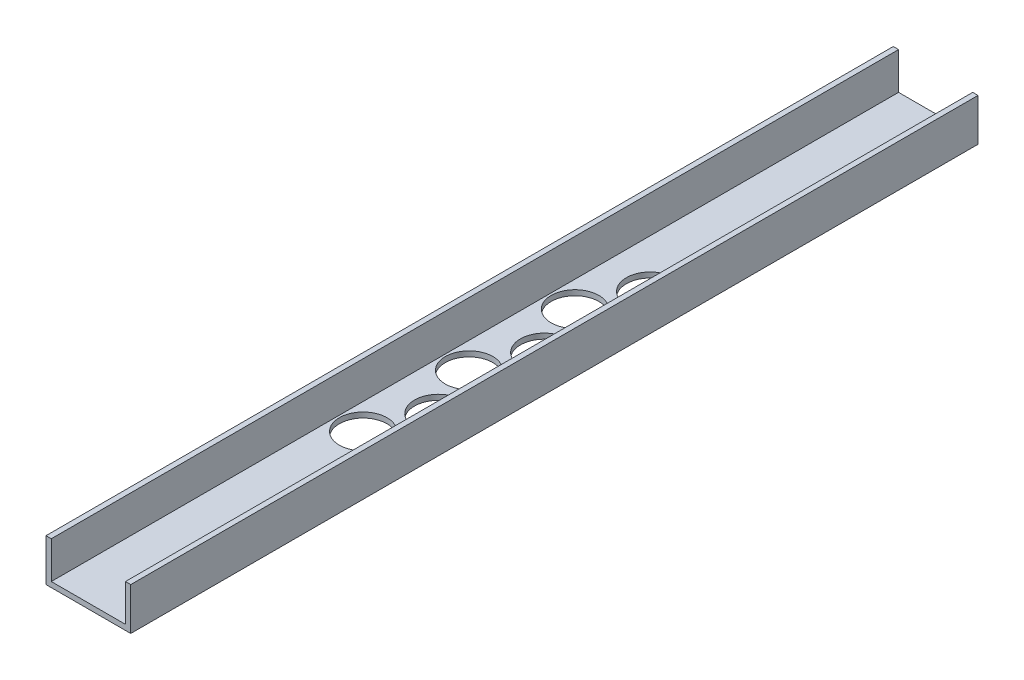
from build123d import *

# Parameters (mm, degrees)
BOSS_EXTRUDE1_DEPTH = 508
CUT_EXTRUDE1_REACH  = 5.175
SKETCH2_R           = 14.2875


with BuildPart() as part:
    # Sketch1 → Boss-Extrude1 (new body)
    with BuildSketch(Plane.XY):
        Polygon((47.625, 3.175), (47.625, 25.4), (50.8, 25.4), (50.8, 0), (0, 0), (0, 25.4), (3.175, 25.4), (3.175, 3.175), align=None)
    extrude(amount=BOSS_EXTRUDE1_DEPTH)

    # Sketch2 → Cut-Extrude1 (cut, up to next)
    with BuildSketch(Plane(origin=(0, 3.175, 0), x_dir=(1, 0, 0), z_dir=(0, 1, 0)), mode=Mode.PRIVATE) as cut_extrude1_sk1:
        with Locations((18.7325, -336.55)):
            Circle(SKETCH2_R)
    cut_extrude1_tool1 = extrude(cut_extrude1_sk1.sketch, amount=-CUT_EXTRUDE1_REACH, mode=Mode.PRIVATE) & part.part
    add(cut_extrude1_tool1.solids().sort_by_distance((18.7325, 3.175, 336.55))[0], mode=Mode.SUBTRACT)
    # Sketch2 → Cut-Extrude1 (cut, up to next)
    with BuildSketch(Plane(origin=(0, 3.175, 0), x_dir=(1, 0, 0), z_dir=(0, 1, 0)), mode=Mode.PRIVATE) as cut_extrude1_sk2:
        with Locations((32.0675, -304.8)):
            Circle(SKETCH2_R)
    cut_extrude1_tool2 = extrude(cut_extrude1_sk2.sketch, amount=-CUT_EXTRUDE1_REACH, mode=Mode.PRIVATE) & part.part
    add(cut_extrude1_tool2.solids().sort_by_distance((32.0675, 3.175, 304.8))[0], mode=Mode.SUBTRACT)
    # Sketch2 → Cut-Extrude1 (cut, up to next)
    with BuildSketch(Plane(origin=(0, 3.175, 0), x_dir=(1, 0, 0), z_dir=(0, 1, 0)), mode=Mode.PRIVATE) as cut_extrude1_sk3:
        with Locations((18.7325, -273.05)):
            Circle(SKETCH2_R)
    cut_extrude1_tool3 = extrude(cut_extrude1_sk3.sketch, amount=-CUT_EXTRUDE1_REACH, mode=Mode.PRIVATE) & part.part
    add(cut_extrude1_tool3.solids().sort_by_distance((18.7325, 3.175, 273.05))[0], mode=Mode.SUBTRACT)
    # Sketch2 → Cut-Extrude1 (cut, up to next)
    with BuildSketch(Plane(origin=(0, 3.175, 0), x_dir=(1, 0, 0), z_dir=(0, 1, 0)), mode=Mode.PRIVATE) as cut_extrude1_sk4:
        with Locations((32.0675, -241.3)):
            Circle(SKETCH2_R)
    cut_extrude1_tool4 = extrude(cut_extrude1_sk4.sketch, amount=-CUT_EXTRUDE1_REACH, mode=Mode.PRIVATE) & part.part
    add(cut_extrude1_tool4.solids().sort_by_distance((32.0675, 3.175, 241.3))[0], mode=Mode.SUBTRACT)
    # Sketch2 → Cut-Extrude1 (cut, up to next)
    with BuildSketch(Plane(origin=(0, 3.175, 0), x_dir=(1, 0, 0), z_dir=(0, 1, 0)), mode=Mode.PRIVATE) as cut_extrude1_sk5:
        with Locations((18.7325, -209.55)):
            Circle(SKETCH2_R)
    cut_extrude1_tool5 = extrude(cut_extrude1_sk5.sketch, amount=-CUT_EXTRUDE1_REACH, mode=Mode.PRIVATE) & part.part
    add(cut_extrude1_tool5.solids().sort_by_distance((18.7325, 3.175, 209.55))[0], mode=Mode.SUBTRACT)
    # Sketch2 → Cut-Extrude1 (cut, up to next)
    with BuildSketch(Plane(origin=(0, 3.175, 0), x_dir=(1, 0, 0), z_dir=(0, 1, 0)), mode=Mode.PRIVATE) as cut_extrude1_sk6:
        with Locations((32.0675, -177.8)):
            Circle(SKETCH2_R)
    cut_extrude1_tool6 = extrude(cut_extrude1_sk6.sketch, amount=-CUT_EXTRUDE1_REACH, mode=Mode.PRIVATE) & part.part
    add(cut_extrude1_tool6.solids().sort_by_distance((32.0675, 3.175, 177.8))[0], mode=Mode.SUBTRACT)


solid = part.part
